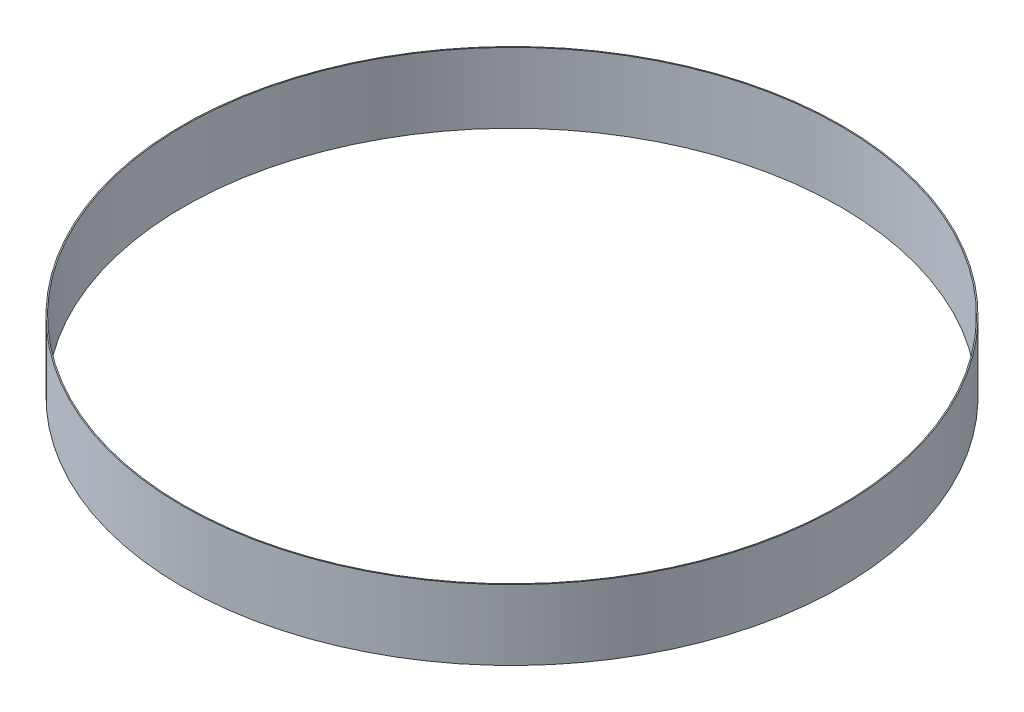
from build123d import *

# Parameters (mm, degrees)
SKETCH1_R           = 150.5
BOSS_EXTRUDE1_DEPTH = 32
SKETCH5_R           = 150
CUT_EXTRUDE1_DEPTH  = 32


with BuildPart() as part:
    # Sketch1 → Boss-Extrude1 (new body)
    with BuildSketch(Plane(origin=(0, 0, 0), x_dir=(1, 0, 0), z_dir=(0, 1, 0))):
        Circle(SKETCH1_R)
    extrude(amount=BOSS_EXTRUDE1_DEPTH)

    # Sketch5 → Cut-Extrude1 (cut)
    with BuildSketch(Plane(origin=(0, 32, 0), x_dir=(1, 0, 0), z_dir=(0, 1, 0))):
        Circle(SKETCH5_R)
    extrude(amount=-CUT_EXTRUDE1_DEPTH, mode=Mode.SUBTRACT)


solid = part.part
